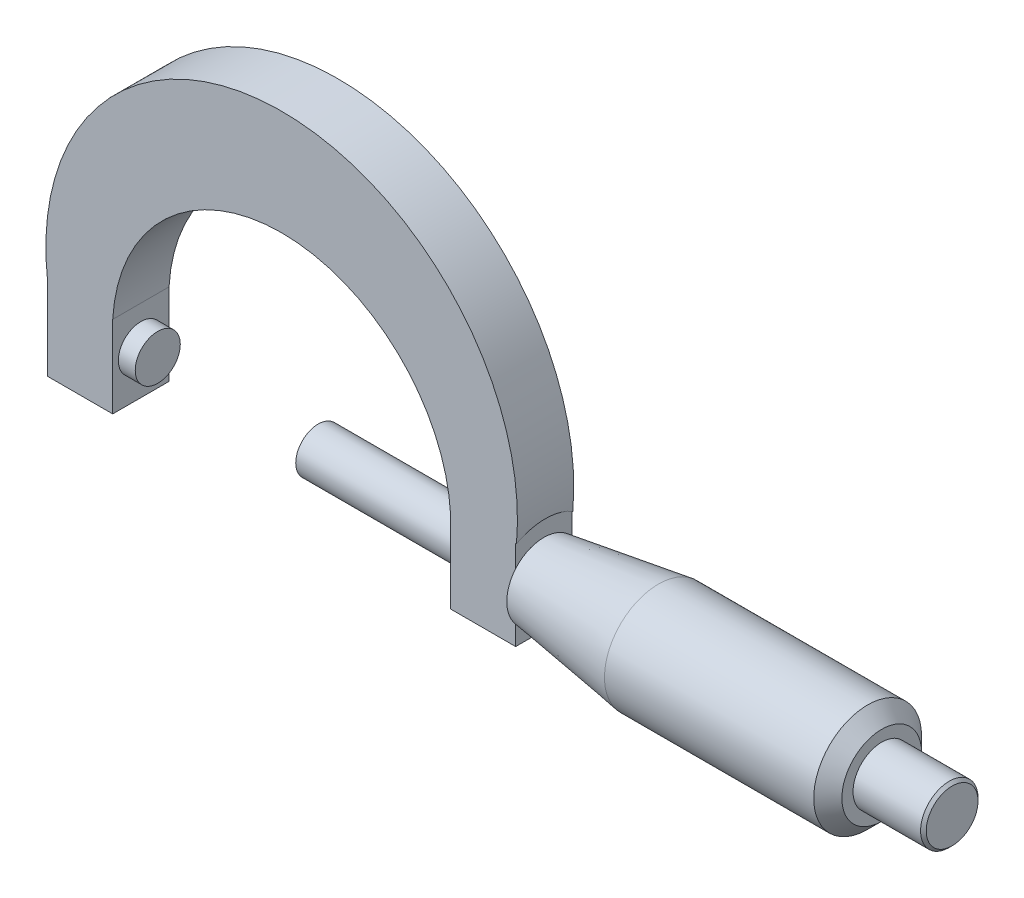
from build123d import *

# Parameters (mm, degrees)
BOSS_EXTRUDE1_DEPTH = 2.54
SKETCH3_R           = 4.865340766
BOSS_EXTRUDE2_DEPTH = 30.48
CHAMFER5_SIZE       = 1.27
SKETCH5_R           = 2.590082511
BOSS_EXTRUDE3_DEPTH = 6.35
CHAMFER6_SIZE       = 0.254
SKETCH6_R           = 2.032
BOSS_EXTRUDE4_DEPTH = 1.524
SKETCH7_R           = 2.032
BOSS_EXTRUDE5_DEPTH = 14.478


with BuildPart() as part:
    # Sketch2 → Boss-Extrude1 (new body, symmetric)
    with BuildSketch(Plane.XY):
        with BuildLine():
            Line((-21.110510204, -3.916551019), (-15.24, -3.916551019))
            Line((-15.24, -3.916551019), (-15.24, 3.470183675))
            ThreePointArc((-15.24, 3.470183675), (-10.479530006, 13.693144777), (0, 17.858533009))
            Line((0, 17.858533009), (0, 27.35528296))
            ThreePointArc((0, 27.35528296), (-15.938566505, 20.170697643), (-21.110510204, 3.470183675))
            Line((-21.110510204, 3.470183675), (-21.110510204, -3.916551019))
        make_face()
    boss_extrude1 = extrude(amount=BOSS_EXTRUDE1_DEPTH, both=True)

    # Mirror1: Boss-Extrude1 across plane
    add(boss_extrude1.mirror(Plane(origin=(0, 0, 0), x_dir=(0, 0, 1), z_dir=(1, 0, 0))))

    # Sketch3 → Boss-Extrude2 (add)
    with BuildSketch(Plane(origin=(21.110510204, 0, 0), x_dir=(0, 0, -1), z_dir=(1, 0, 0))):
        Circle(SKETCH3_R)
    extrude(amount=BOSS_EXTRUDE2_DEPTH)

    # Sketch4 → Cut-Revolve1 (revolve, cut)
    with BuildSketch(Plane.XY):
        Polygon((21.110510204, 3.342420759), (21.110510204, 4.865340766), (31.445897446, 4.865340766), align=None)
    revolve(axis=Axis((51.590510204, 0, 0), (-1, 0, 0)), mode=Mode.SUBTRACT)

    # Chamfer5
    chamfer5_edges = [part.edges().sort_by_distance(p)[0] for p in [
        (51.590510204, 0, 4.865340766),
    ]]
    chamfer(chamfer5_edges, length=CHAMFER5_SIZE)

    # Sketch5 → Boss-Extrude3 (add)
    with BuildSketch(Plane(origin=(51.590510204, 0, 0), x_dir=(0, 0, -1), z_dir=(1, 0, 0))):
        Circle(SKETCH5_R)
    extrude(amount=BOSS_EXTRUDE3_DEPTH)

    # Chamfer6
    chamfer6_edges = [part.edges().sort_by_distance(p)[0] for p in [
        (57.940510204, 0, 2.590082511),
    ]]
    chamfer(chamfer6_edges, length=CHAMFER6_SIZE)

    # Sketch6 → Boss-Extrude4 (add)
    with BuildSketch(Plane(origin=(-15.24, 0, 0), x_dir=(0, 0, -1), z_dir=(1, 0, 0))):
        Circle(SKETCH6_R)
    extrude(amount=BOSS_EXTRUDE4_DEPTH)

    # Sketch7 → Boss-Extrude5 (add)
    with BuildSketch(Plane.ZY.offset(-15.24)):
        Circle(SKETCH7_R)
    extrude(amount=BOSS_EXTRUDE5_DEPTH)


solid = part.part
